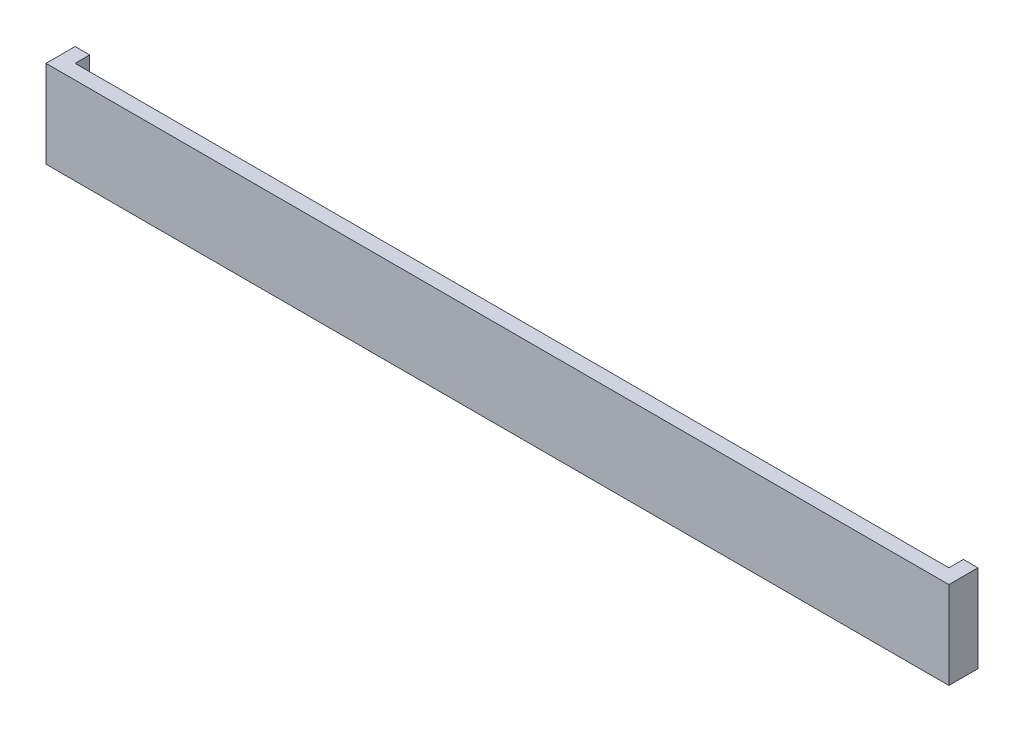
from build123d import *

# Parameters (mm, degrees)
SKETCH2_W           = 620
SKETCH2_H           = 60
BOSS_EXTRUDE1_DEPTH = 20
SKETCH4_W           = 600
SKETCH4_H           = 10
CUT_EXTRUDE1_DEPTH  = 100


with BuildPart() as part:
    # Sketch2 → Boss-Extrude1 (new body)
    with BuildSketch(Plane.XY):
        Rectangle(SKETCH2_W, SKETCH2_H)
    extrude(amount=BOSS_EXTRUDE1_DEPTH)

    # Sketch4 → Cut-Extrude1 (cut)
    with BuildSketch(Plane(origin=(0, 30, 0), x_dir=(1, 0, 0), z_dir=(0, 1, 0))):
        with Locations((0, -5)):
            Rectangle(SKETCH4_W, SKETCH4_H)
    extrude(amount=-CUT_EXTRUDE1_DEPTH, mode=Mode.SUBTRACT)


solid = part.part
